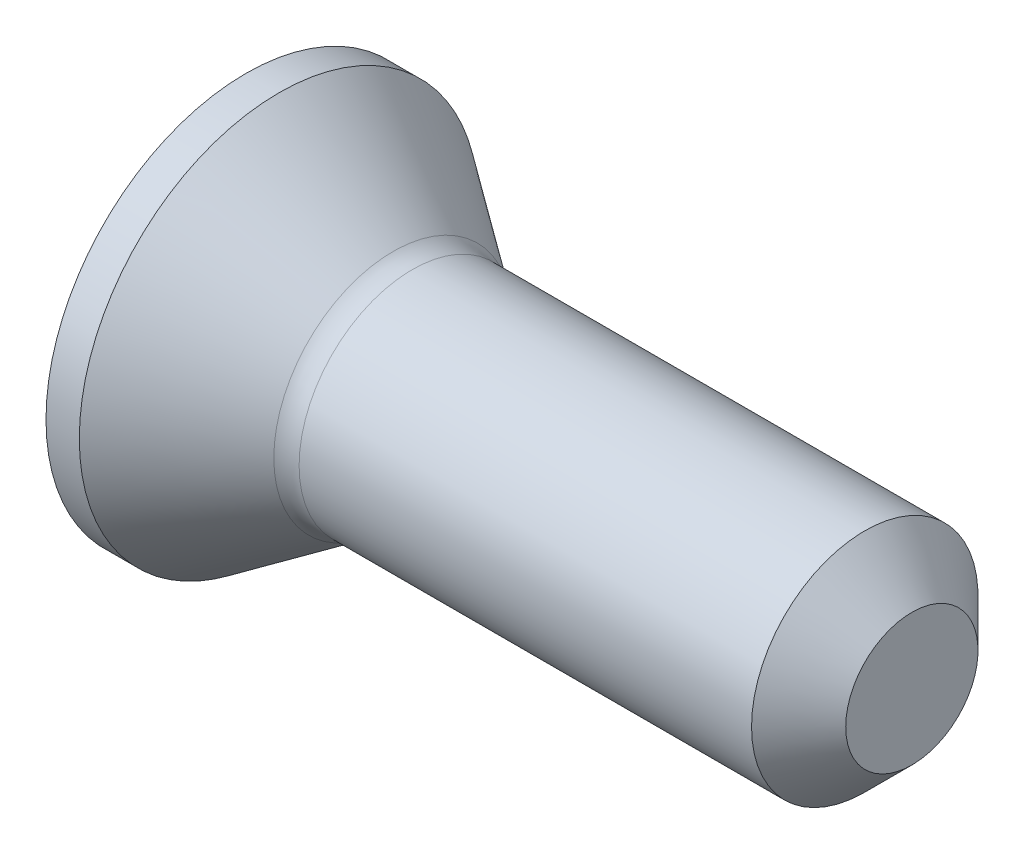
from build123d import *

# Parameters (mm, degrees)
CUT_EXTRUDE1_DEPTH = 0.5


with BuildPart() as part:
    # Sketch1 → Revolve1 (revolve)
    with BuildSketch(Plane.XY):
        with BuildLine():
            Line((0, 0), (0, 1.5))
            Line((0, 1.5), (0.25, 1.5))
            Line((0.25, 1.5), (1.105808936, 0.89577234))
            ThreePointArc((1.105808936, 0.89577234), (1.174359121, 0.861717694), (1.25, 0.85))
            Line((1.25, 0.85), (4.646446609, 0.85))
            Line((4.646446609, 0.85), (5, 0.496446609))
            Line((5, 0.496446609), (5, 0))
            Line((5, 0), (0, 0))
        make_face()
    revolve(axis=Axis((-3.974685283, 0, 0), (1, 0, 0)))

    # Sketch2 → Cut-Extrude1 (cut)
    with BuildSketch(Plane.ZY):
        Polygon((-0.175, 0.75), (0.175, 0.75), (0.221258856, 0.221258856), (0.75, 0.175), (0.75, -0.175), (0.221258856, -0.221258856), (0.175, -0.75), (-0.175, -0.75), (-0.221258856, -0.221258856), (-0.75, -0.175), (-0.75, 0.175), (-0.221258856, 0.221258856), align=None)
    extrude(amount=-CUT_EXTRUDE1_DEPTH, mode=Mode.SUBTRACT)


solid = part.part
